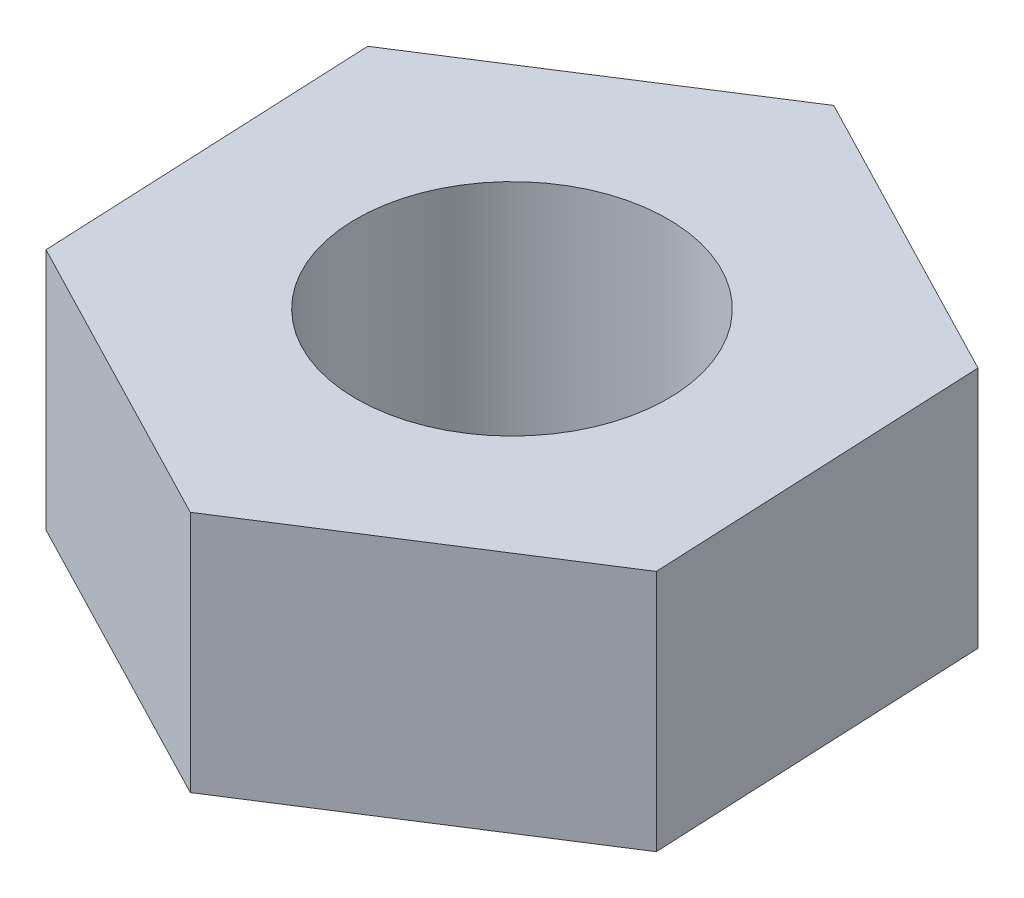
from build123d import *

# Parameters (mm, degrees)
BOSS_EXTRUDE1_DEPTH = 2.025
CUT_EXTRUDE1_REACH  = 6.05
SKETCH2_R           = 2.6


with BuildPart() as part:
    # Sketch1 → Boss-Extrude1 (new body, symmetric)
    with BuildSketch(Plane(origin=(0, 0, 0), x_dir=(1, 0, 0), z_dir=(0, 1, 0))):
        Polygon((4.742197554, 3.032995609), (-0.25555247, 5.623361356), (-4.997750023, 2.590365747), (-4.742197554, -3.032995609), (0.25555247, -5.623361356), (4.997750023, -2.590365747), align=None)
    extrude(amount=BOSS_EXTRUDE1_DEPTH, both=True)

    # Sketch2 → Cut-Extrude1 (cut, up to next)
    with BuildSketch(Plane(origin=(0, 2.025, 0), x_dir=(1, 0, 0), z_dir=(0, 1, 0)), mode=Mode.PRIVATE) as cut_extrude1_sk1:
        Circle(SKETCH2_R)
    cut_extrude1_tool1 = extrude(cut_extrude1_sk1.sketch, amount=-CUT_EXTRUDE1_REACH, mode=Mode.PRIVATE) & part.part
    add(cut_extrude1_tool1.solids().sort_by_distance((0, 2.025, 0))[0], mode=Mode.SUBTRACT)


solid = part.part
